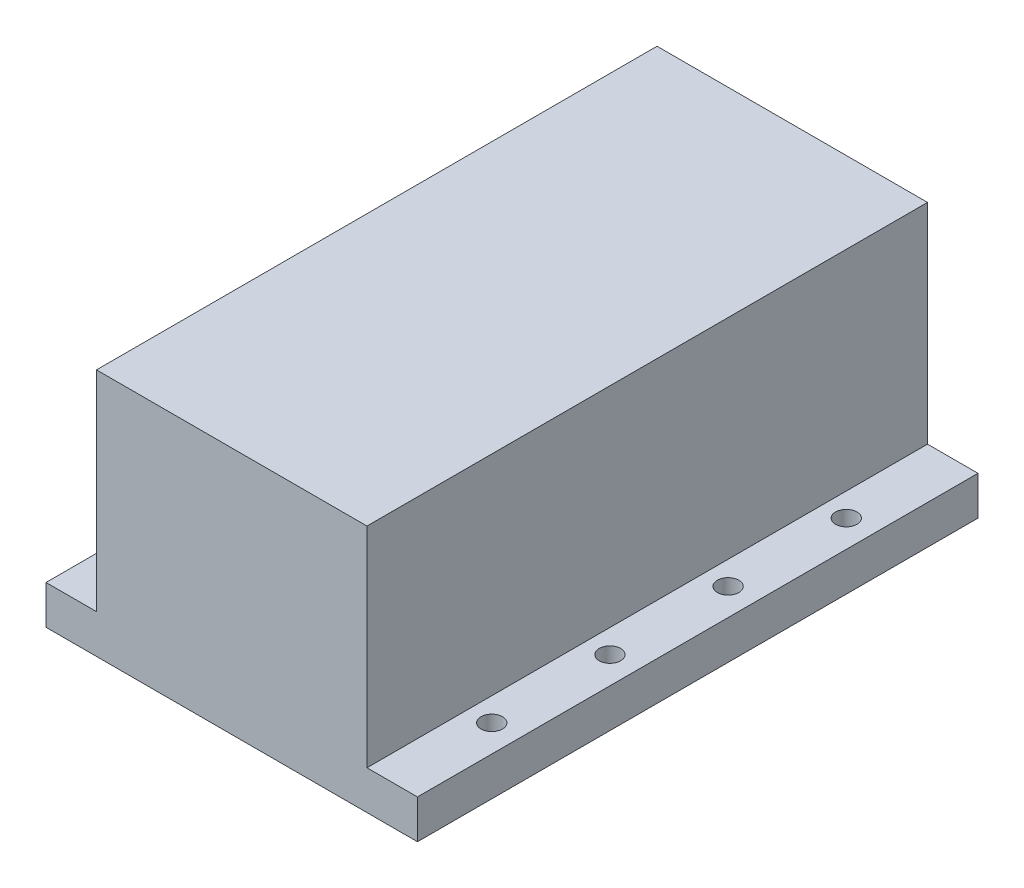
from build123d import *

# Parameters (mm, degrees)
SKETCH1_W           = 110
SKETCH1_H           = 166
SKETCH1_R           = 3.175
BOSS_EXTRUDE1_DEPTH = 11.5
SKETCH2_W           = 80.1
SKETCH2_H           = 166
BOSS_EXTRUDE2_DEPTH = 62


with BuildPart() as part:
    # Sketch1 → Boss-Extrude1 (new body)
    with BuildSketch(Plane(origin=(0, 0, 0), x_dir=(1, 0, 0), z_dir=(0, 1, 0))):
        with Locations((55, 83)):
            Rectangle(SKETCH1_W, SKETCH1_H)
        with Locations((8, 135)):
            Circle(SKETCH1_R, mode=Mode.SUBTRACT)
        with Locations((102, 135)):
            Circle(SKETCH1_R, mode=Mode.SUBTRACT)
        with Locations((102, 100)):
            Circle(SKETCH1_R, mode=Mode.SUBTRACT)
        with Locations((102, 65)):
            Circle(SKETCH1_R, mode=Mode.SUBTRACT)
        with Locations((102, 30)):
            Circle(SKETCH1_R, mode=Mode.SUBTRACT)
        with Locations((8, 100)):
            Circle(SKETCH1_R, mode=Mode.SUBTRACT)
        with Locations((8, 65)):
            Circle(SKETCH1_R, mode=Mode.SUBTRACT)
        with Locations((8, 30)):
            Circle(SKETCH1_R, mode=Mode.SUBTRACT)
    extrude(amount=BOSS_EXTRUDE1_DEPTH)

    # Sketch2 → Boss-Extrude2 (add)
    with BuildSketch(Plane(origin=(0, 11.5, 0), x_dir=(1, 0, 0), z_dir=(0, 1, 0))):
        with Locations((55, 83)):
            Rectangle(SKETCH2_W, SKETCH2_H)
    extrude(amount=BOSS_EXTRUDE2_DEPTH)


solid = part.part
